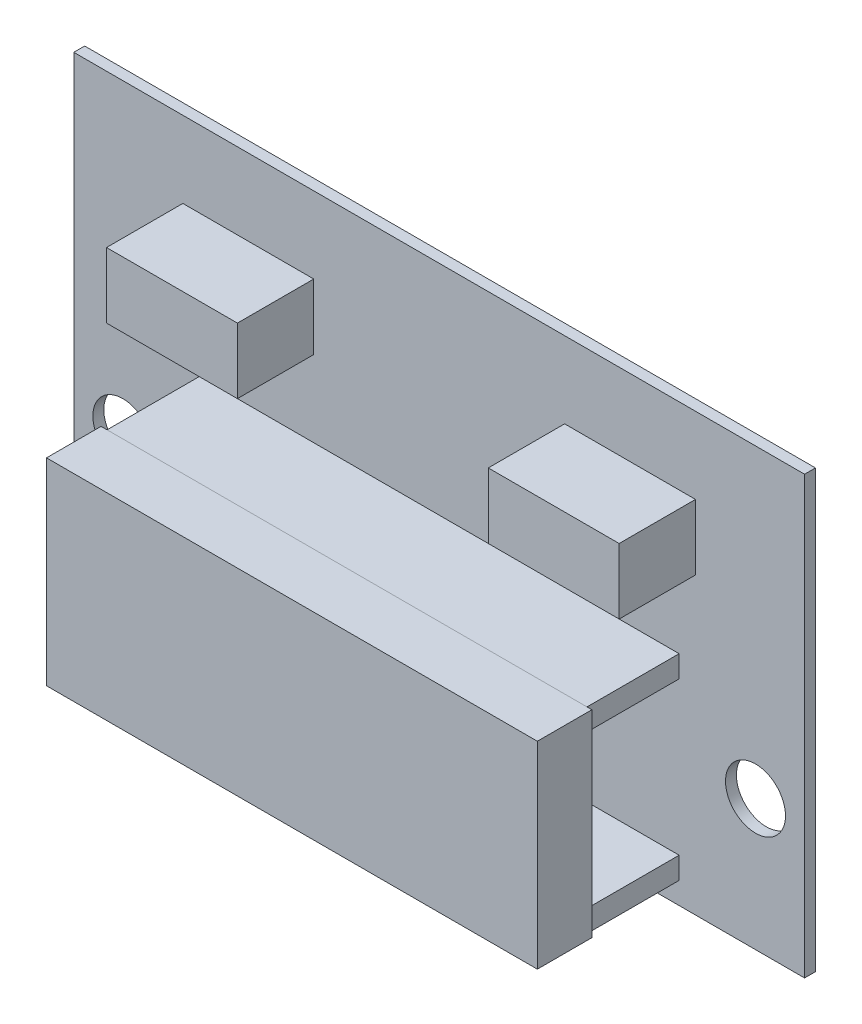
from build123d import *

# Parameters (mm, degrees)
SKETCH_1_W          = 67
SKETCH_1_H          = 40
EXTRUDE_1_DEPTH     = 1
SKETCH_2_W          = 44
SKETCH_2_H          = 2
EXTRUDE_2_DEPTH     = 8.5
SKETCH_3_W          = 45
SKETCH_3_H          = 18.1
EXTRUDE_3_DEPTH     = 5
SKETCH_4_R          = 2.75
CUT_EXTRUDE_1_DEPTH = 5
SKETCH_5_W          = 12
SKETCH_5_H          = 6
EXTRUDE_4_DEPTH     = 7


with BuildPart() as part:
    # ｽｹｯﾁ1 → ﾎﾞｽ - 押し出し1 (new body)
    with BuildSketch(Plane.XY):
        Rectangle(SKETCH_1_W, SKETCH_1_H)
    extrude(amount=EXTRUDE_1_DEPTH)

    # ｽｹｯﾁ2 → ﾎﾞｽ - 押し出し2 (add)
    with BuildSketch(Plane.XY.offset(1)):
        with Locations((0, -1)):
            Rectangle(SKETCH_2_W, SKETCH_2_H)
        with Locations((0, -17)):
            Rectangle(SKETCH_2_W, SKETCH_2_H)
    extrude(amount=EXTRUDE_2_DEPTH)

    # ｽｹｯﾁ3 → ﾎﾞｽ - 押し出し3 (add)
    with BuildSketch(Plane.XY.offset(9.5)):
        with Locations((0, -9)):
            Rectangle(SKETCH_3_W, SKETCH_3_H)
    extrude(amount=EXTRUDE_3_DEPTH)

    # ｽｹｯﾁ4 → ｶｯﾄ - 押し出し1 (cut)
    with BuildSketch(Plane.XY.offset(1)):
        with Locations((-29, -8)):
            Circle(SKETCH_4_R)
        with Locations((29, -8)):
            Circle(SKETCH_4_R)
    extrude(amount=-CUT_EXTRUDE_1_DEPTH, mode=Mode.SUBTRACT)

    # ｽｹｯﾁ5 → ﾎﾞｽ - 押し出し4 (add)
    with BuildSketch(Plane.XY.offset(1)):
        with Locations((-17.5, 10)):
            Rectangle(SKETCH_5_W, SKETCH_5_H)
        with Locations((17.5, 10)):
            Rectangle(SKETCH_5_W, SKETCH_5_H)
    extrude(amount=EXTRUDE_4_DEPTH)


solid = part.part
